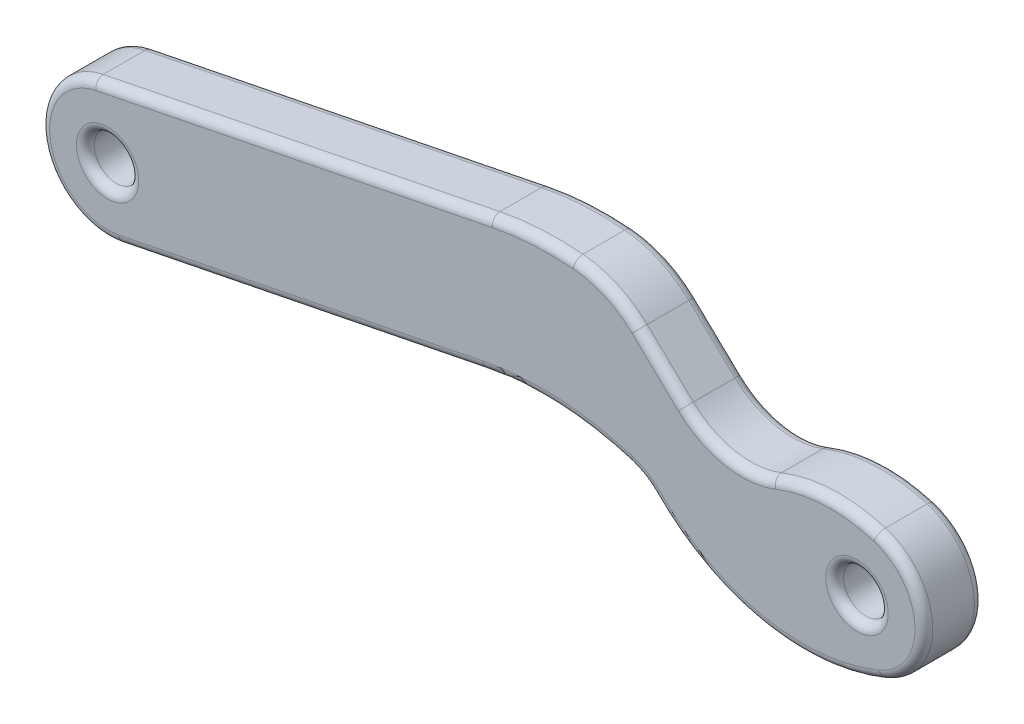
from build123d import *

# Parameters (mm, degrees)
SKETCH1_R               = 0.75
BOSS_EXTRUDE1_DEPTH     = 2
SKETCH3_OUTSIDE_W       = 37.736
SKETCH3_OUTSIDE_H       = 12.524
CUT_EXTRUDE4_DEPTH      = 3
SKETCH4_R               = 0.75
BOSS_EXTRUDE2_DEPTH     = 2
CUT_EXTRUDE6_DEPTH      = 3
CUT_EXTRUDE6_DEPTH_BACK = 1
BOSS_EXTRUDE3_DEPTH     = 2
FILLET1_R               = 0.3


with BuildPart() as part:
    # Sketch1 → Boss-Extrude1 (new body)
    with BuildSketch(Plane.XY):
        with BuildLine():
            Line((0, 2.25), (25.212458, 2.25))
            ThreePointArc((25.212458, 2.25), (27.462458, 0), (25.212458, -2.25))
            Line((25.212458, -2.25), (0, -2.25))
            ThreePointArc((0, -2.25), (-2.25, 0), (0, 2.25))
        make_face()
        Circle(SKETCH1_R, mode=Mode.SUBTRACT)
        with Locations((25.212458, 0)):
            Circle(SKETCH1_R, mode=Mode.SUBTRACT)
    extrude(amount=BOSS_EXTRUDE1_DEPTH)

    # Sketch3 outside → Cut-Extrude4 (cut, through all)
    with BuildSketch(Plane.XY):
        with Locations((12.606, 0)):
            Rectangle(SKETCH3_OUTSIDE_W, SKETCH3_OUTSIDE_H)
        with BuildLine():
            Line((0.442179, -2.206123), (12.676166, 0.245967))
            ThreePointArc((12.676166, 0.245967), (15.133584, 0.427523), (17.56033, 0))
            Line((17.56033, 0), (24.550878, -2.150537))
            ThreePointArc((24.550878, -2.150537), (27.362996, -0.661581), (25.874039, 2.150537))
            Line((25.874039, 2.150537), (17.804394, 4.633043))
            ThreePointArc((17.804394, 4.633043), (15.366999, 5.062442), (12.898796, 4.880089))
            Line((12.898796, 4.880089), (-0.442179, 2.206123))
            ThreePointArc((-0.442179, 2.206123), (-2.206123, -0.442179), (0.442179, -2.206123))
        make_face(mode=Mode.SUBTRACT)
    extrude(amount=CUT_EXTRUDE4_DEPTH, mode=Mode.SUBTRACT)

    # Sketch4 → Boss-Extrude2 (add)
    with BuildSketch(Plane.XY.offset(2)):
        with BuildLine():
            Line((12.898796, 4.880089), (-0.442179, 2.206123))
            ThreePointArc((-0.442179, 2.206123), (-2.206123, -0.442179), (0.442179, -2.206123))
            Line((0.442179, -2.206123), (12.676166, 0.245967))
            ThreePointArc((12.676166, 0.245967), (15.133584, 0.427523), (17.56033, 0))
            Line((17.56033, 0), (24.550878, -2.150537))
            ThreePointArc((24.550878, -2.150537), (27.362996, -0.661581), (25.874039, 2.150537))
            Line((25.874039, 2.150537), (17.804394, 4.633043))
            ThreePointArc((17.804394, 4.633043), (15.366999, 5.062442), (12.898796, 4.880089))
        make_face()
        with Locations((25.212458, 0)):
            Circle(SKETCH4_R, mode=Mode.SUBTRACT)
        Circle(SKETCH4_R, mode=Mode.SUBTRACT)
    extrude(amount=-BOSS_EXTRUDE2_DEPTH)

    # Sketch6 → Cut-Extrude6 (cut, two sides)
    with BuildSketch(Plane.XY) as cut_extrude6_sk:
        with BuildLine():
            Line((15.698135, 5.040252), (20.735888, 8.302002))
            Line((20.735888, 8.302002), (25.874039, 2.150537))
            ThreePointArc((25.874039, 2.150537), (24.112991, 2.379465), (22.3758, 2.010862))
            ThreePointArc((22.3758, 2.010862), (20.807854, 1.8643), (19.40879, 2.587179))
            Line((19.40879, 2.587179), (17.854664, 4.070121))
            ThreePointArc((17.854664, 4.070121), (16.859472, 4.73985), (15.698135, 5.040252))
        make_face()
    extrude(amount=CUT_EXTRUDE6_DEPTH, mode=Mode.SUBTRACT)
    extrude(cut_extrude6_sk.sketch, amount=-CUT_EXTRUDE6_DEPTH_BACK, mode=Mode.SUBTRACT)

    # Sketch7 → Boss-Extrude3 (add)
    with BuildSketch(Plane.XY.offset(2)):
        with BuildLine():
            Line((17.56033, 0), (19.46651, 0.56554))
            Line((19.46651, 0.56554), (26.068277, -2.080883))
            ThreePointArc((26.068277, -2.080883), (21.974936, -2.464238), (18.367439, -0.492343))
            ThreePointArc((18.367439, -0.492343), (17.994729, -0.195607), (17.56033, 0))
        make_face()
    extrude(amount=-BOSS_EXTRUDE3_DEPTH)

    # Fillet1
    fillet1_edges = [part.edges().sort_by_distance(p)[0] for p in [
        (24.462458, 0, 0),
        (-0.75, 0, 0),
        (6.559172, -0.980078, 0),
        (15.133584, 0.427523, 0),
        (24.462458, 0, 0),
        (14.292824, 5.058771, 2),
        (14.292824, 5.058771, 0),
        (6.228309, 3.543106, 2),
        (6.228309, 3.543106, 0),
        (-2.206123, -0.442179, 0),
        (24.462458, 0, 2),
        (-0.75, 0, 2),
        (27.460091, 0.103175, 2),
        (15.133584, 0.427523, 2),
        (6.559172, -0.980078, 2),
        (-2.206123, -0.442179, 2),
        (24.112991, 2.379465, 0),
        (20.807854, 1.8643, 0),
        (16.859472, 4.73985, 0),
        (24.112991, 2.379465, 2),
        (16.859472, 4.73985, 2),
        (20.807854, 1.8643, 2),
        (21.974936, -2.464238, 2),
        (21.974936, -2.464238, 0),
        (17.994729, -0.195607, 2),
        (17.994729, -0.195607, 0),
        (18.631727, 3.32865, 0),
        (18.631727, 3.32865, 2),
    ]]
    fillet(fillet1_edges, radius=FILLET1_R)


solid = part.part
